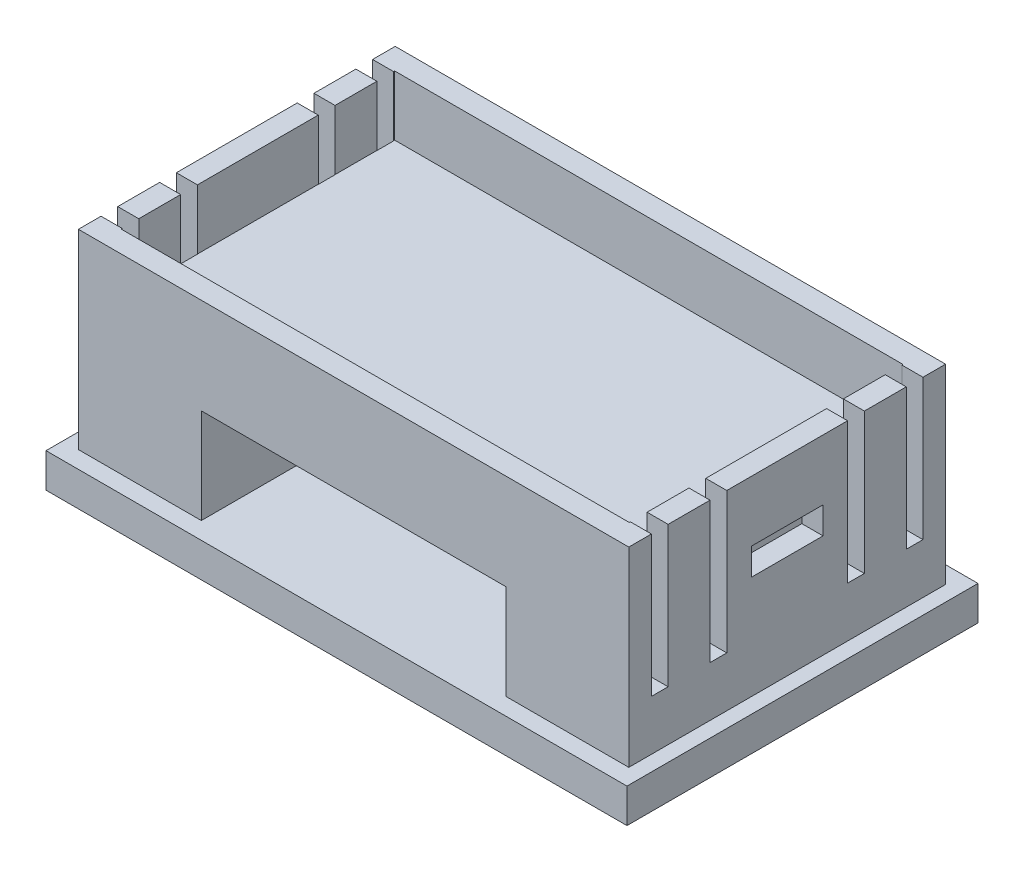
from build123d import *

# Parameters (mm, degrees)
SKETCH3_W           = 47.5
SKETCH3_H           = 28.7
BOSS_EXTRUDE2_DEPTH = 2.8
SKETCH4_W           = 45
SKETCH4_H           = 25.9
BOSS_EXTRUDE3_DEPTH = 15.6
SKETCH5_W           = 24.9
SKETCH5_H           = 7.77
CUT_EXTRUDE1_DEPTH  = 12.95
SKETCH6_W           = 41.56
SKETCH6_H           = 22.38
CUT_EXTRUDE2_DEPTH  = 4.9
SKETCH7_W           = 1.37
SKETCH7_H           = 11.5
SKETCH7_W_2         = 1.364312096
SKETCH7_W_3         = 5.86
SKETCH7_H_2         = 2.2
CUT_EXTRUDE4_DEPTH  = 1.73


with BuildPart() as part:
    # Sketch3 → Boss-Extrude2 (new body)
    with BuildSketch(Plane(origin=(0, 0, 0), x_dir=(1, 0, 0), z_dir=(0, 1, 0))):
        Rectangle(SKETCH3_W, SKETCH3_H)
    extrude(amount=BOSS_EXTRUDE2_DEPTH)

    # Sketch4 → Boss-Extrude3 (add)
    with BuildSketch(Plane(origin=(0, 2.8, 0), x_dir=(1, 0, 0), z_dir=(0, 1, 0))):
        Rectangle(SKETCH4_W, SKETCH4_H)
    extrude(amount=BOSS_EXTRUDE3_DEPTH)

    # Sketch5 → Cut-Extrude1 (cut)
    with BuildSketch(Plane.XY):
        with Locations((0, 6.685)):
            Rectangle(SKETCH5_W, SKETCH5_H)
    cut_extrude1 = extrude(amount=-CUT_EXTRUDE1_DEPTH, mode=Mode.SUBTRACT)

    # Mirror1: Cut-Extrude1 across plane
    add(cut_extrude1.mirror(Plane.XY), mode=Mode.SUBTRACT)

    # Sketch6 → Cut-Extrude2 (cut)
    with BuildSketch(Plane(origin=(0, 18.4, 0), x_dir=(1, 0, 0), z_dir=(0, 1, 0))):
        Rectangle(SKETCH6_W, SKETCH6_H)
    extrude(amount=-CUT_EXTRUDE2_DEPTH, mode=Mode.SUBTRACT)

    # Sketch7 → Cut-Extrude4 (cut)
    with BuildSketch(Plane(origin=(22.5, 0, 0), x_dir=(0, 0, -1), z_dir=(1, 0, 0))):
        with Locations((5.625, 12.65)):
            Rectangle(SKETCH7_W, SKETCH7_H)
        with Locations((10.417843952, 12.65)):
            Rectangle(SKETCH7_W_2, SKETCH7_H)
        with Locations((0, 12.35)):
            Rectangle(SKETCH7_W_3, SKETCH7_H_2)
        with Locations((-5.625, 12.65)):
            Rectangle(SKETCH7_W, SKETCH7_H)
        with Locations((-10.417843952, 12.65)):
            Rectangle(SKETCH7_W_2, SKETCH7_H)
    cut_extrude4 = extrude(amount=-CUT_EXTRUDE4_DEPTH, mode=Mode.SUBTRACT)

    # Mirror2: Cut-Extrude4 across plane
    add(cut_extrude4.mirror(Plane(origin=(0, 0, 0), x_dir=(0, 0, 1), z_dir=(1, 0, 0))), mode=Mode.SUBTRACT)


solid = part.part
